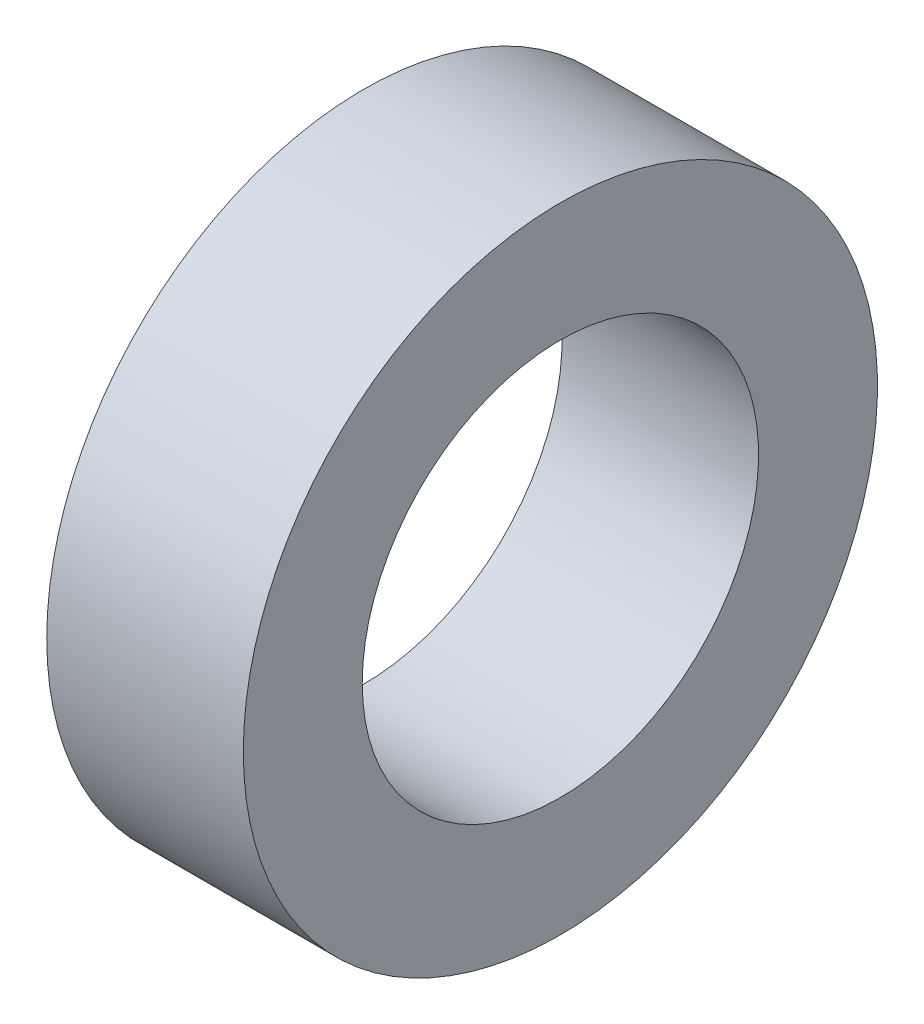
from build123d import *

# Parameters (mm, degrees)
SKETCH3_W = 2.48000012
SKETCH3_H = 1.500000048


with BuildPart() as part:
    # Sketch3 → Revolve1 (revolve)
    with BuildSketch(Plane.XY):
        with Locations((14.879799806, 3.249999977)):
            Rectangle(SKETCH3_W, SKETCH3_H)
    revolve(axis=Axis((0, 0, 0), (1, 0, 0)))


solid = part.part
